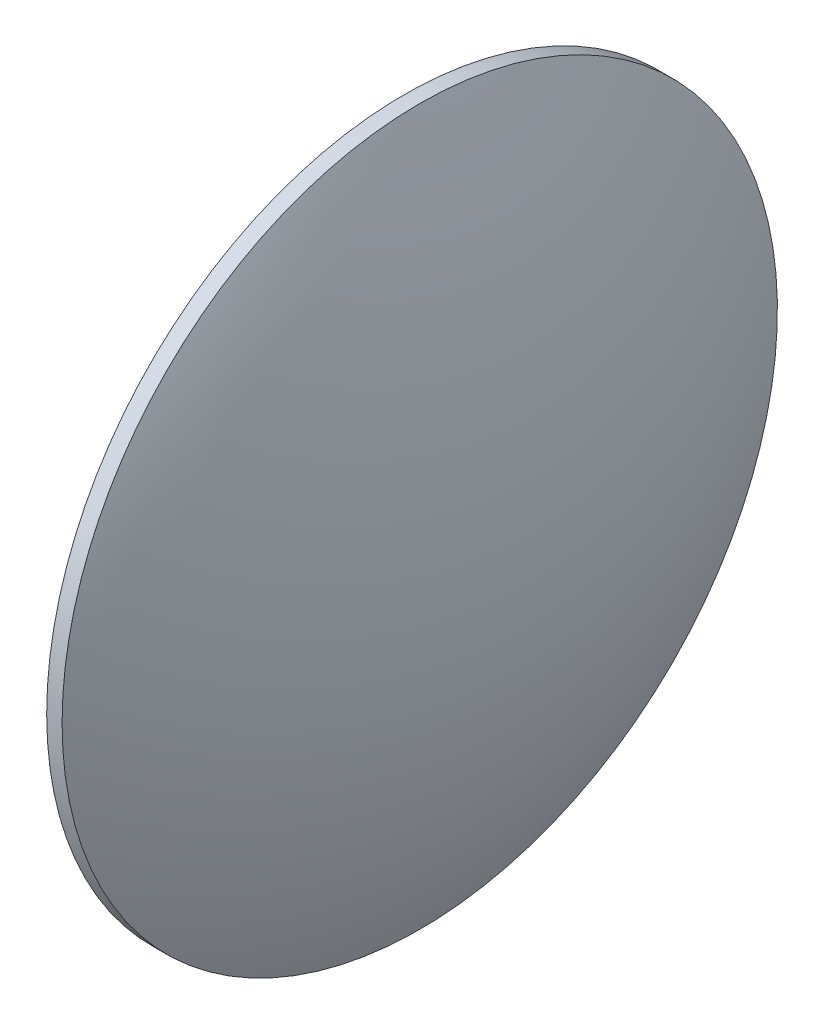
from build123d import *


with BuildPart() as part:
    # 草图1 → 旋转1 (revolve)
    with BuildSketch(Plane.XY):
        with BuildLine():
            Line((191.859466539, -255.60567035), (191.859466539, -233.10567035))
            Line((191.859466539, -233.10567035), (192.829466539, -233.10567035))
            ThreePointArc((192.829466539, -233.10567035), (196.660718805, -244.066964833), (197.959466539, -255.60567035))
            Line((197.959466539, -255.60567035), (191.859466539, -255.60567035))
        make_face()
    revolve(axis=Axis((187.816345069, -255.60567035, 0), (1, 0, 0)))


solid = part.part
